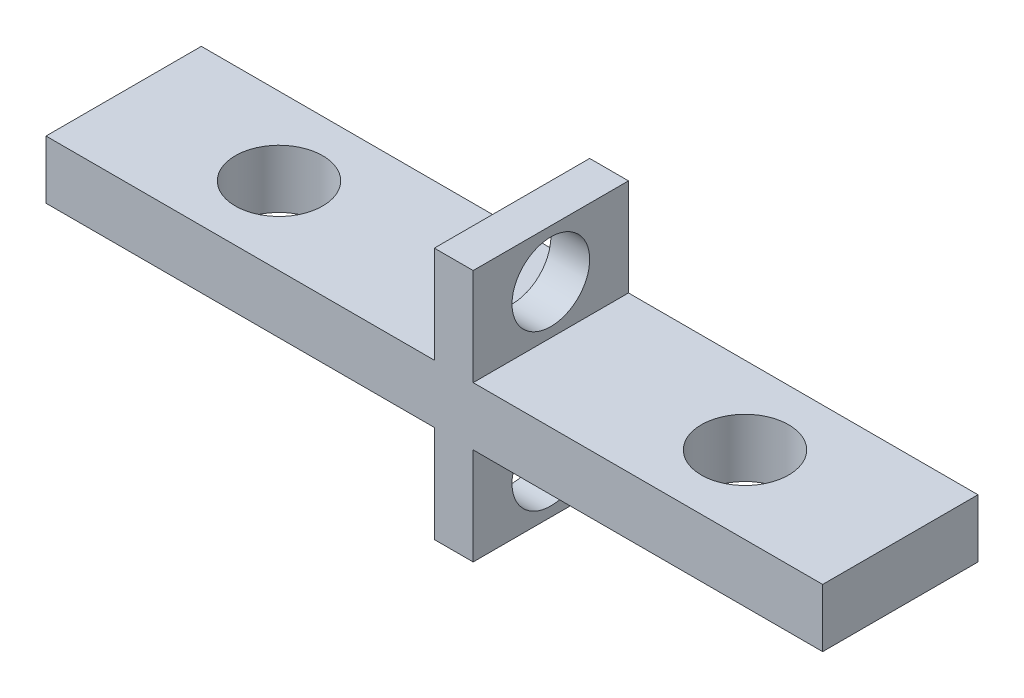
from build123d import *

# Parameters (mm, degrees)
SKETCH1_W                 = 40
SKETCH1_H                 = 8
BOSS_EXTRUDE1_DEPTH       = 3
F_8_CLEARANCE_HOLE1_D     = 4.4958
F_8_CLEARANCE_HOLE1_DEPTH = 17
F_8_CLEARANCE_HOLE1_TIP   = 1.350674586
SKETCH5_W                 = 2
SKETCH5_H                 = 8
BOSS_EXTRUDE2_DEPTH       = 5
BOSS_EXTRUDE2_DEPTH_BACK  = 8
SKETCH6_R                 = 2
CUT_EXTRUDE1_DEPTH        = 2


with BuildPart() as part:
    # Sketch1 → Boss-Extrude1 (new body)
    with BuildSketch(Plane(origin=(0, 0, 0), x_dir=(1, 0, 0), z_dir=(0, 1, 0))):
        with Locations((12.773632998, 0.313559322)):
            Rectangle(SKETCH1_W, SKETCH1_H)
    extrude(amount=BOSS_EXTRUDE1_DEPTH)

    # #8 Clearance Hole1
    with Locations(Plane(origin=(0.773632998, 3, -0.313559322), x_dir=(0, 0, 1), z_dir=(0, 1, 0))):
        with Locations((0, 0), (0, 24)):
            Hole(F_8_CLEARANCE_HOLE1_D / 2, depth=F_8_CLEARANCE_HOLE1_DEPTH)
            with Locations((0, 0, -(F_8_CLEARANCE_HOLE1_DEPTH + F_8_CLEARANCE_HOLE1_TIP / 2))):  # 118° drill point
                Cone(0, F_8_CLEARANCE_HOLE1_D / 2, F_8_CLEARANCE_HOLE1_TIP, mode=Mode.SUBTRACT)

    # Sketch5 → Boss-Extrude2 (add, two sides)
    with BuildSketch(Plane(origin=(0, 3, 0), x_dir=(1, 0, 0), z_dir=(0, 1, 0))) as boss_extrude2_sk:
        with Locations((13.773632998, 0.313559322)):
            Rectangle(SKETCH5_W, SKETCH5_H)
    extrude(amount=BOSS_EXTRUDE2_DEPTH)
    extrude(boss_extrude2_sk.sketch, amount=-BOSS_EXTRUDE2_DEPTH_BACK)

    # Sketch6 → Cut-Extrude1 (cut)
    with BuildSketch(Plane.ZY.offset(-12.773632998)):
        with Locations((-0.313559322, 5.5)):
            Circle(SKETCH6_R)
        with Locations((-0.313559322, -2.5)):
            Circle(SKETCH6_R)
    extrude(amount=-CUT_EXTRUDE1_DEPTH, mode=Mode.SUBTRACT)


solid = part.part
